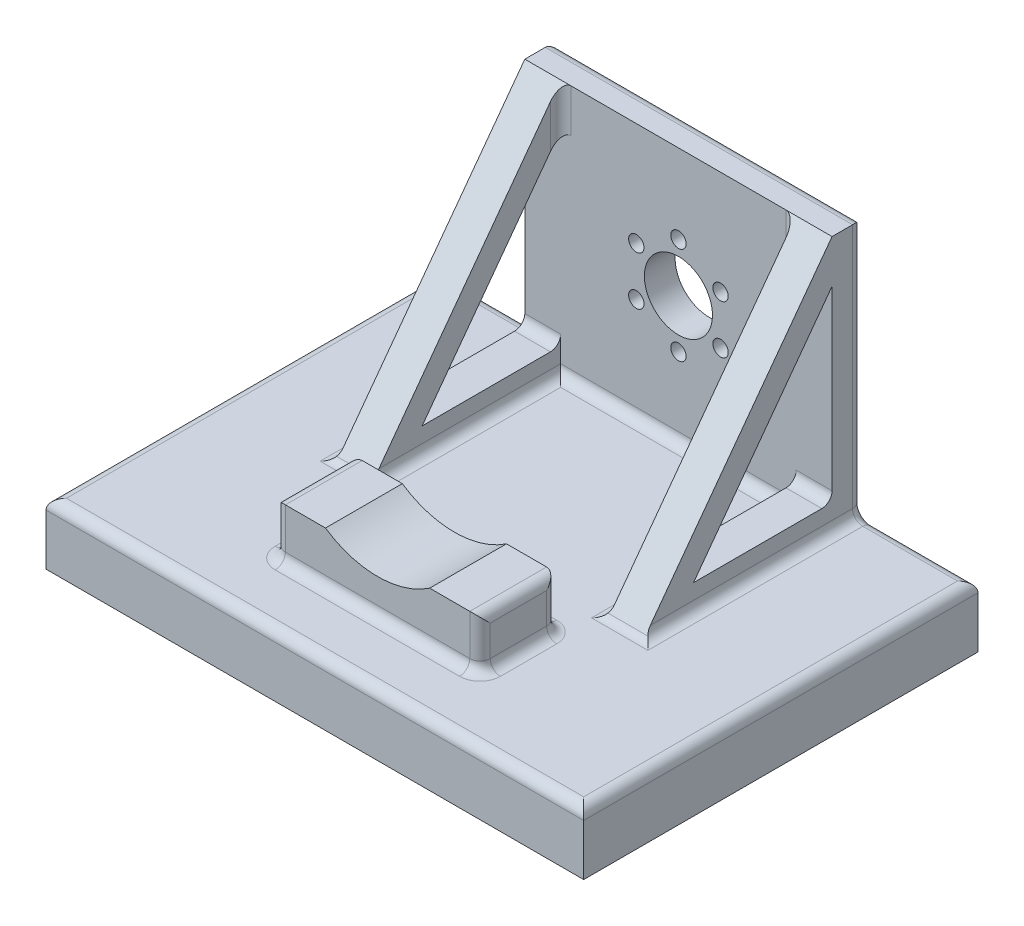
from build123d import *

# Parameters (mm, degrees)
BOSS_EXTRUDE1_DEPTH = 52.5
SKETCH6_W           = 40
SKETCH6_H           = 15
BOSS_EXTRUDE3_DEPTH = 10
SKETCH9_R           = 6.65
SKETCH9_R_2         = 1.5
CUT_EXTRUDE4_DEPTH  = 78
CIRPATTERN2_COUNT   = 6
SKETCH10_R          = 18.125
CUT_EXTRUDE5_DEPTH  = 72
FILLET3_R           = 2
SKETCH11_W          = 22.5
SKETCH11_H          = 50
CUT_EXTRUDE6_DEPTH  = 7
BOSS_EXTRUDE4_DEPTH = 7
CUT_EXTRUDE8_DEPTH  = 83.5
FILLET5_R           = 2


with BuildPart() as part:
    # Sketch1 → Boss-Extrude1 (new body, symmetric)
    with BuildSketch(Plane(origin=(0, 0, 0), x_dir=(0, 0, -1), z_dir=(1, 0, 0))):
        Polygon((0, 0), (0, 50), (6, 50), (6, -12), (-71, -12), (-71, 0), align=None)
    extrude(amount=BOSS_EXTRUDE1_DEPTH, both=True)

    # Sketch6 → Boss-Extrude3 (add)
    with BuildSketch(Plane(origin=(0, 0, 0), x_dir=(1, 0, 0), z_dir=(0, 1, 0))):
        with Locations((0, -51.25)):
            Rectangle(SKETCH6_W, SKETCH6_H)
    extrude(amount=BOSS_EXTRUDE3_DEPTH)

    # Sketch9 → Cut-Extrude4 (cut, through all)
    with BuildSketch(Plane(origin=(0, 0, -6), x_dir=(-1, 0, 0), z_dir=(0, 0, -1))):
        with Locations((0, 25)):
            Circle(SKETCH9_R)
        with Locations((0, 34.5)):
            Circle(SKETCH9_R_2)
    cut_extrude4 = extrude(amount=-CUT_EXTRUDE4_DEPTH, mode=Mode.SUBTRACT)

    # CirPattern2: Cut-Extrude4 ×6 about axis
    cirpattern2_axis = Axis((0, 25, 0), (0, 0, 1))
    for i in range(1, CIRPATTERN2_COUNT):
        add(cut_extrude4.rotate(cirpattern2_axis, i * 360 / CIRPATTERN2_COUNT), mode=Mode.SUBTRACT)

    # Sketch10 → Cut-Extrude5 (cut, through all)
    with BuildSketch(Plane.XY):
        with Locations((0, 25)):
            Circle(SKETCH10_R)
    extrude(amount=CUT_EXTRUDE5_DEPTH, mode=Mode.SUBTRACT)

    # Fillet3
    fillet3_edges = [part.edges().sort_by_distance(p)[0] for p in [
        (-20, 0, 51.25),
        (-20, 5, 43.75),
        (0, 0, 58.75),
        (-20, 5, 58.75),
        (20, 0, 51.25),
        (20, 5, 58.75),
        (0, 0, 43.75),
        (20, 5, 43.75),
        (-20, 10, 51.25),
        (20, 10, 51.25),
    ]]
    fillet(fillet3_edges, radius=FILLET3_R)

    # Sketch11 → Cut-Extrude6 (cut, through all)
    with BuildSketch(Plane.XY):
        with Locations((-41.25, 25)):
            Rectangle(SKETCH11_W, SKETCH11_H)
    cut_extrude6 = extrude(amount=-CUT_EXTRUDE6_DEPTH, mode=Mode.SUBTRACT)

    # Mirror1: Cut-Extrude6 across plane
    add(cut_extrude6.mirror(Plane(origin=(0, 0, 0), x_dir=(0, 0, 1), z_dir=(1, 0, 0))), mode=Mode.SUBTRACT)

    # Sketch13 → Boss-Extrude4 (add)
    with BuildSketch(Plane(origin=(30, 0, 0), x_dir=(0, 0, -1), z_dir=(1, 0, 0))):
        Polygon((0, 0), (-36.962201233, 0), (0, 50), align=None)
    boss_extrude4 = extrude(amount=-BOSS_EXTRUDE4_DEPTH)

    # Sketch14 → Cut-Extrude8 (cut, through all)
    with BuildSketch(Plane(origin=(30, 0, 0), x_dir=(0, 0, -1), z_dir=(1, 0, 0))):
        Polygon((-27.048100185, 5), (0, 5), (0, 41.588865493), align=None)
    cut_extrude8 = extrude(amount=-CUT_EXTRUDE8_DEPTH, mode=Mode.SUBTRACT)

    # Mirror2: Boss-Extrude4, Cut-Extrude8 across plane
    add(boss_extrude4.mirror(Plane(origin=(0, 0, 0), x_dir=(0, 0, 1), z_dir=(1, 0, 0))))
    add(cut_extrude8.mirror(Plane(origin=(0, 0, 0), x_dir=(0, 0, 1), z_dir=(1, 0, 0))), mode=Mode.SUBTRACT)

    # Fillet5
    fillet5_edges = [part.edges().sort_by_distance(p)[0] for p in [
        (30, 25, -6),
        (-30, 25, -6),
        (23, 0, 18.481100617),
        (26.5, 0, 36.962201233),
        (30, 0, 15.481100617),
        (41.25, 0, -6),
        (52.5, 0, 32.5),
        (0, 0, 71),
        (-52.5, 0, 32.5),
        (-41.25, 0, -6),
        (-30, 0, 15.481100617),
        (-26.5, 0, 36.962201233),
        (-23, 0, 18.481100617),
        (0, 0, 0),
        (0, 50, -6),
        (23, 45.794432746, 0),
        (-23, 45.794432746, 0),
        (26.5, 5, 0),
        (-26.5, 5, 0),
    ]]
    fillet(fillet5_edges, radius=FILLET5_R)


solid = part.part
